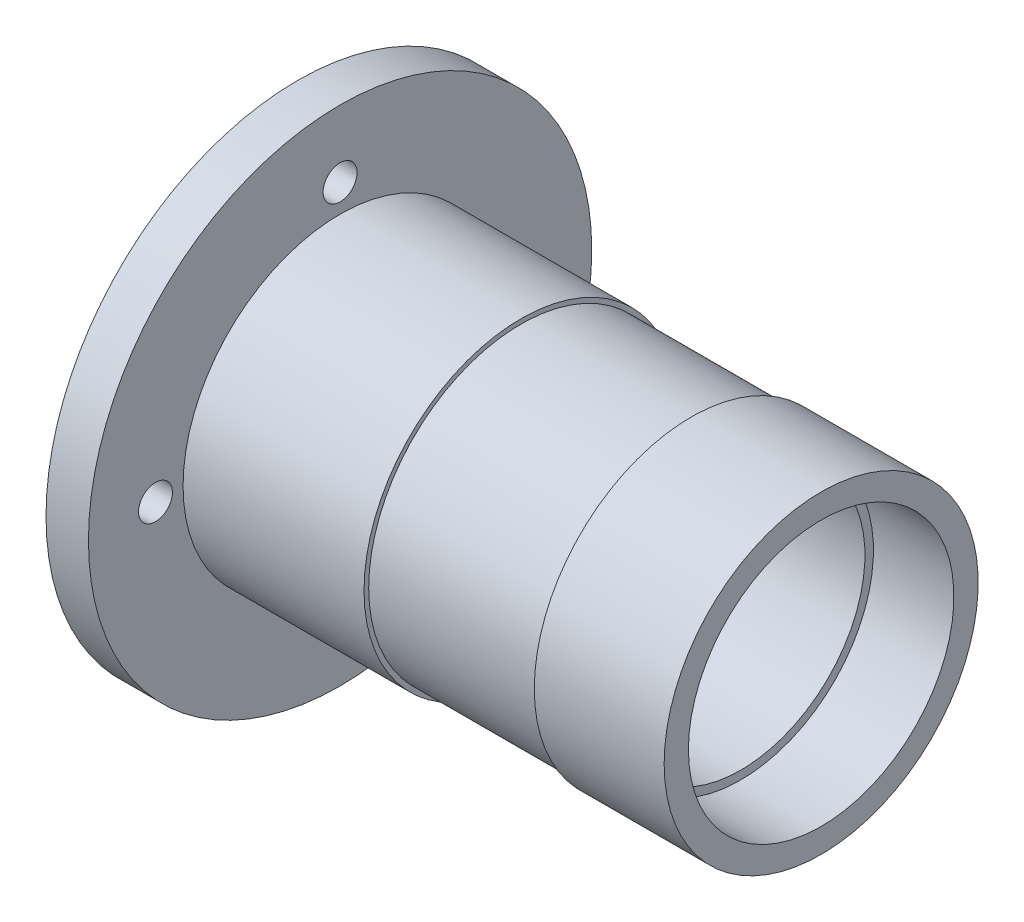
from build123d import *

# Parameters (mm, degrees)
SKETCH_2_R          = 4
CUT_EXTRUDE_1_DEPTH = 124.36


with BuildPart() as part:
    # 草图1 → 旋转1 (revolve)
    with BuildSketch(Plane.XY):
        Polygon((73.298050743, 37), (42.698050743, 37), (42.698050743, 35.9), (2.578050743, 35.9), (2.578050743, 37), (-40.061949257, 37), (-40.061949257, 59.300299501), (-50.061949257, 59.300299501), (-50.061949257, 31.28), (-9.061949257, 31.28), (-9.061949257, 29.28), (54.338050743, 29.28), (54.338050743, 31.28), (73.298050743, 31.28), align=None)
    revolve(axis=Axis((-67.043189493, 0, 0), (1, 0, 0)))

    # 草图2 → 切除-拉伸1 (cut, through all)
    with BuildSketch(Plane.ZY.offset(50.061949257)):
        with Locations((0, 43.5)):
            Circle(SKETCH_2_R)
        with Locations((43.5, 0)):
            Circle(SKETCH_2_R)
        with Locations((0, -43.5)):
            Circle(SKETCH_2_R)
        with Locations((-43.5, 0)):
            Circle(SKETCH_2_R)
    extrude(amount=-CUT_EXTRUDE_1_DEPTH, mode=Mode.SUBTRACT)


solid = part.part
